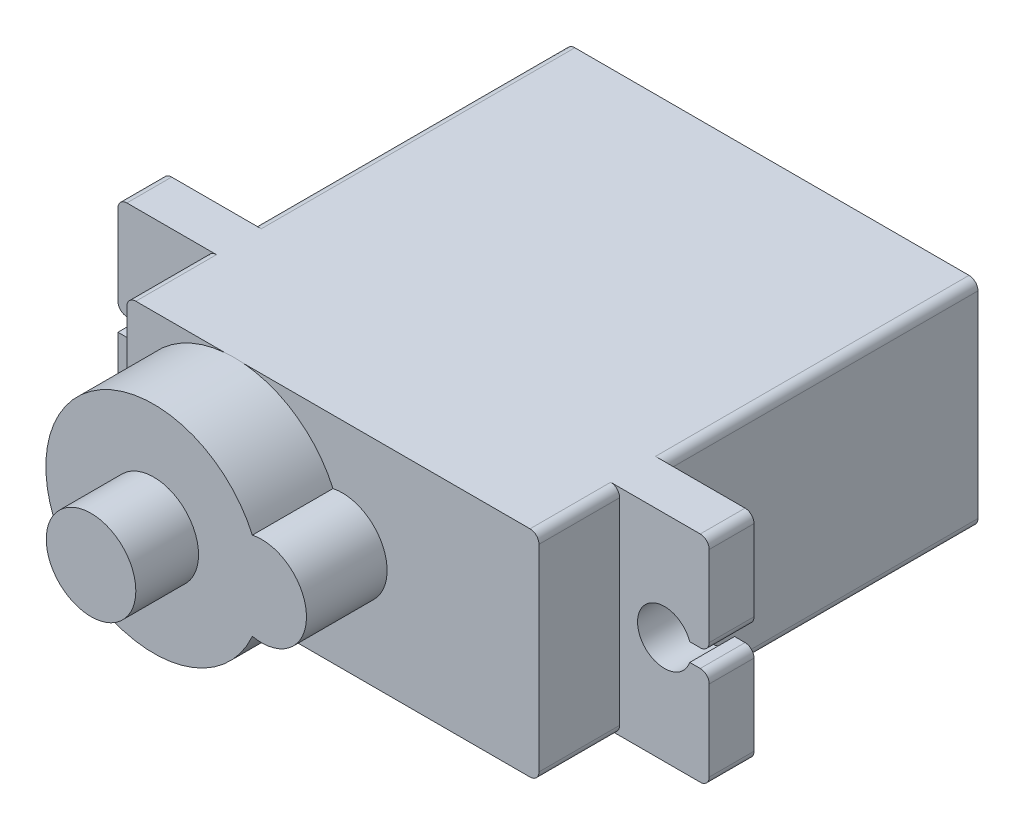
from build123d import *

# Parameters (mm, degrees)
ESQUISSE1_W             = 23
ESQUISSE1_H             = 12
BOSS_EXTRU_1_DEPTH      = 17.5
ESQUISSE2_W             = 33
ESQUISSE2_H             = 12
BOSS_EXTRU_2_DEPTH      = 2.5
ESQUISSE3_W             = 23
ESQUISSE3_H             = 12
BOSS_EXTRU_3_DEPTH      = 4.5
ESQUISSE4_R             = 6.022589187
BOSS_EXTRU_4_DEPTH      = 4.5
ESQUISSE5_R             = 2.5
BOSS_EXTRU_5_DEPTH      = 4.5
ESQUISSE6_R             = 2.5
BOSS_EXTRU_6_DEPTH      = 3.5
ENL_V_MAT_EXTRU_3_DEPTH = 21
CONG_2_R                = 0.5


with BuildPart() as part:
    # Esquisse1 → Boss.-Extru.1 (new body)
    with BuildSketch(Plane.XY):
        with Locations((-4.910575451, 4.41260745)):
            Rectangle(ESQUISSE1_W, ESQUISSE1_H)
    extrude(amount=BOSS_EXTRU_1_DEPTH)

    # Esquisse2 → Boss.-Extru.2 (add)
    with BuildSketch(Plane.XY.offset(17.5)):
        with Locations((-4.910575451, 4.41260745)):
            Rectangle(ESQUISSE2_W, ESQUISSE2_H)
    extrude(amount=BOSS_EXTRU_2_DEPTH)

    # Esquisse3 → Boss.-Extru.3 (add)
    with BuildSketch(Plane.XY.offset(20)):
        with Locations((-4.910575451, 4.41260745)):
            Rectangle(ESQUISSE3_W, ESQUISSE3_H)
    extrude(amount=BOSS_EXTRU_3_DEPTH)

    # Esquisse4 → Boss.-Extru.4 (add)
    with BuildSketch(Plane.XY.offset(24.5)):
        with Locations((-10.410575451, 4.41260745)):
            Circle(ESQUISSE4_R)
    extrude(amount=BOSS_EXTRU_4_DEPTH)

    # Esquisse5 → Boss.-Extru.5 (add)
    with BuildSketch(Plane.XY.offset(24.5)):
        with Locations((-4.387986264, 4.41260745)):
            Circle(ESQUISSE5_R)
    extrude(amount=BOSS_EXTRU_5_DEPTH)

    # Esquisse6 → Boss.-Extru.6 (add)
    with BuildSketch(Plane.XY.offset(29)):
        with Locations((-10.410575451, 4.41260745)):
            Circle(ESQUISSE6_R)
    extrude(amount=BOSS_EXTRU_6_DEPTH)

    # Esquisse7 → Enlèv. mat.-Extru.3 (cut, through all)
    with BuildSketch(Plane.XY.offset(20)):
        with BuildLine():
            ThreePointArc((-20.324789014, 4.91260745), (-20.410575451, 4.41260745), (-20.324789014, 3.91260745))
            Line((-20.324789014, 3.91260745), (-20.324789014, 4.91260745))
        make_face()
        with BuildLine():
            Line((-20.324789014, 4.91260745), (-20.324789014, 3.91260745))
            ThreePointArc((-20.324789014, 3.91260745), (-18.656922483, 2.93420961), (-17.410575451, 4.41260745))
            ThreePointArc((-17.410575451, 4.41260745), (-18.656922483, 5.891005289), (-20.324789014, 4.91260745))
        make_face()
        with BuildLine():
            Line((-21.410575451, 4.91260745), (-21.410575451, 3.91260745))
            Line((-21.410575451, 3.91260745), (-20.324789014, 3.91260745))
            ThreePointArc((-20.324789014, 3.91260745), (-20.410575451, 4.41260745), (-20.324789014, 4.91260745))
            Line((-20.324789014, 4.91260745), (-21.410575451, 4.91260745))
        make_face()
        with BuildLine():
            ThreePointArc((10.589424549, 4.41260745), (10.567822388, 4.666260418), (10.503638111, 4.91260745))
            Line((10.503638111, 4.91260745), (10.503638111, 3.91260745))
            ThreePointArc((10.503638111, 3.91260745), (10.567822388, 4.158954482), (10.589424549, 4.41260745))
        make_face()
        with BuildLine():
            Line((10.503638111, 3.91260745), (10.503638111, 4.91260745))
            ThreePointArc((10.503638111, 4.91260745), (7.589424549, 4.41260745), (10.503638111, 3.91260745))
        make_face()
        with BuildLine():
            Line((12.675210986, 3.91260745), (12.675210986, 4.91260745))
            Line((12.675210986, 4.91260745), (10.503638111, 4.91260745))
            ThreePointArc((10.503638111, 4.91260745), (10.567822388, 4.666260418), (10.589424549, 4.41260745))
            ThreePointArc((10.589424549, 4.41260745), (10.567822388, 4.158954482), (10.503638111, 3.91260745))
            Line((10.503638111, 3.91260745), (12.675210986, 3.91260745))
        make_face()
    extrude(amount=-ENL_V_MAT_EXTRU_3_DEPTH, mode=Mode.SUBTRACT)

    # Congé2
    cong_2_edges = [part.edges().sort_by_distance(p)[0] for p in [
        (-21.410575451, 10.41260745, 18.75),
        (-21.410575451, -1.58739255, 18.75),
        (11.589424549, -1.58739255, 18.75),
        (11.589424549, 10.41260745, 18.75),
        (-16.410575451, 10.41260745, 22.25),
        (-16.410575451, -1.58739255, 22.25),
        (6.589424549, -1.58739255, 22.25),
        (6.589424549, 10.41260745, 22.25),
        (-21.410575451, 4.91260745, 18.75),
        (-16.410575451, 10.41260745, 8.75),
        (6.589424549, 10.41260745, 8.75),
        (6.589424549, -1.58739255, 8.75),
        (-16.410575451, -1.58739255, 8.75),
        (11.589424549, 4.91260745, 18.75),
        (11.589424549, 3.91260745, 18.75),
    ]]
    fillet(cong_2_edges, radius=CONG_2_R)


solid = part.part
